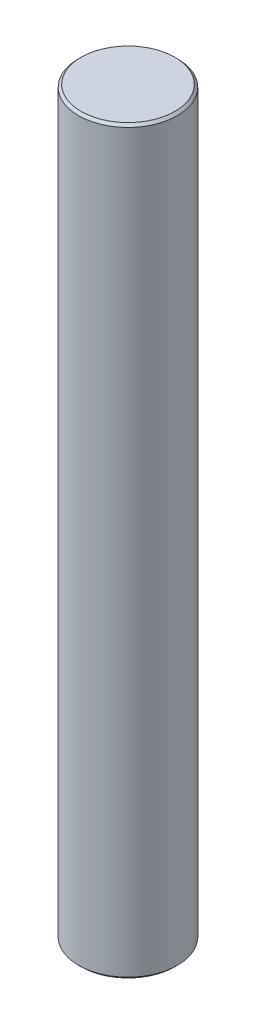
from build123d import *

# Parameters (mm, degrees)
SKETCH1_R           = 2
BOSS_EXTRUDE1_DEPTH = 30
CHAMFER1_SIZE       = 0.1


with BuildPart() as part:
    # Sketch1 → Boss-Extrude1 (new body)
    with BuildSketch(Plane(origin=(0, 0, 0), x_dir=(1, 0, 0), z_dir=(0, 1, 0))):
        Circle(SKETCH1_R)
    extrude(amount=BOSS_EXTRUDE1_DEPTH)

    # Chamfer1
    chamfer1_edges = [part.edges().sort_by_distance(p)[0] for p in [
        (-2, 0, 0),
        (-2, 30, 0),
    ]]
    chamfer(chamfer1_edges, length=CHAMFER1_SIZE)


solid = part.part
